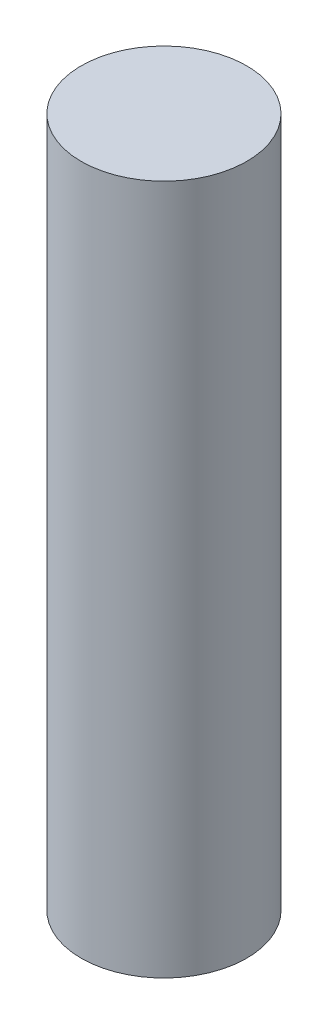
from build123d import *

# Parameters (mm, degrees)
SKETCH1_R           = 6
BOSS_EXTRUDE1_DEPTH = 25


with BuildPart() as part:
    # Sketch1 → Boss-Extrude1 (new body, symmetric)
    with BuildSketch(Plane(origin=(0, 0, 0), x_dir=(1, 0, 0), z_dir=(0, 1, 0))):
        Circle(SKETCH1_R)
    extrude(amount=BOSS_EXTRUDE1_DEPTH, both=True)


solid = part.part
